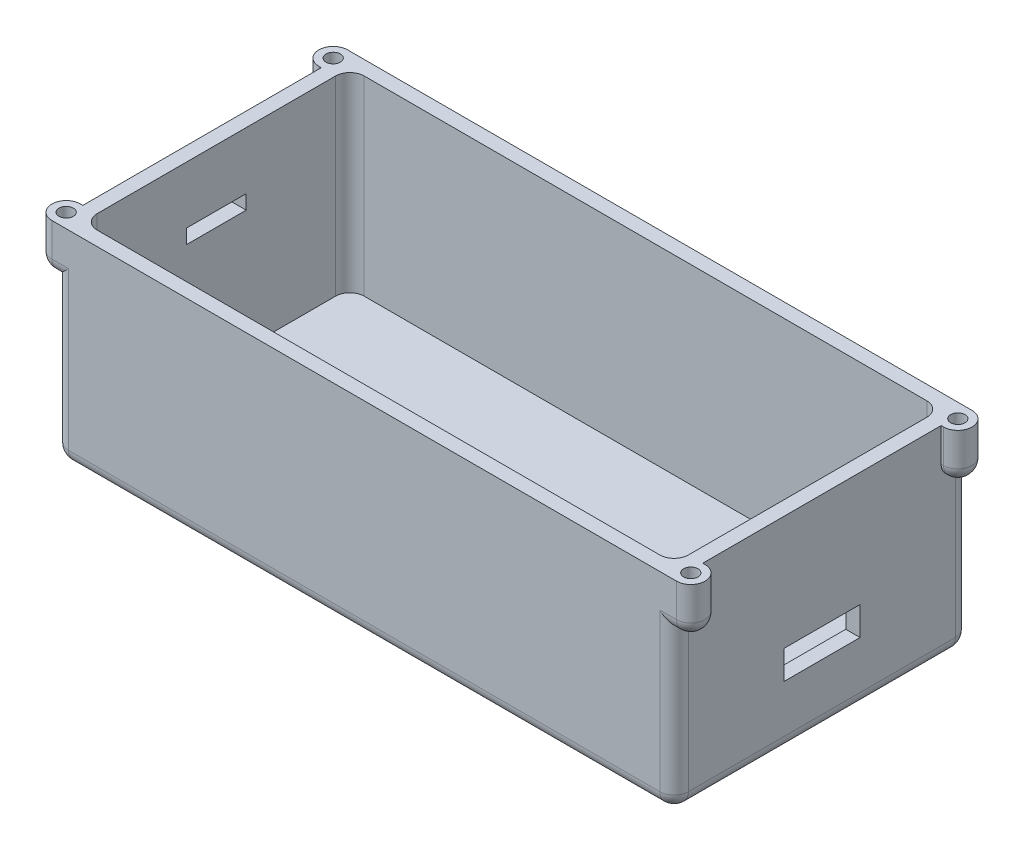
from build123d import *

# Parameters (mm, degrees)
SKETCH1_W           = 130
SKETCH1_H           = 62
BOSS_EXTRUDE1_DEPTH = 3
SKETCH2_W           = 130
SKETCH2_H           = 62
SKETCH2_W_2         = 124
SKETCH2_H_2         = 56
BOSS_EXTRUDE2_DEPTH = 40
CUT_EXTRUDE1_REACH  = 132
SKETCH3_W           = 16
SKETCH3_H           = 6
CUT_EXTRUDE2_REACH  = 132
SKETCH4_W           = 12.5
SKETCH4_H           = 3
BOSS_EXTRUDE3_DEPTH = 10
SKETCH6_R           = 1.5
CUT_EXTRUDE3_DEPTH  = 5
FILLET1_R           = 3
FILLET2_R           = 3
FILLET3_R           = 3


with BuildPart() as part:
    # Sketch1 → Boss-Extrude1 (new body)
    with BuildSketch(Plane(origin=(0, 0, 0), x_dir=(1, 0, 0), z_dir=(0, 1, 0))):
        Rectangle(SKETCH1_W, SKETCH1_H)
    extrude(amount=BOSS_EXTRUDE1_DEPTH)

    # Sketch2 → Boss-Extrude2 (add)
    with BuildSketch(Plane(origin=(0, 3, 0), x_dir=(1, 0, 0), z_dir=(0, 1, 0))):
        Rectangle(SKETCH2_W, SKETCH2_H)
        Rectangle(SKETCH2_W_2, SKETCH2_H_2, mode=Mode.SUBTRACT)
    extrude(amount=BOSS_EXTRUDE2_DEPTH)

    # Sketch3 → Cut-Extrude1 (cut, up to next)
    with BuildSketch(Plane(origin=(65, 0, 0), x_dir=(0, 0, -1), z_dir=(1, 0, 0)), mode=Mode.PRIVATE) as cut_extrude1_sk1:
        with Locations((0, 16)):
            Rectangle(SKETCH3_W, SKETCH3_H)
    cut_extrude1_tool1 = extrude(cut_extrude1_sk1.sketch, amount=-CUT_EXTRUDE1_REACH, mode=Mode.PRIVATE) & part.part
    add(cut_extrude1_tool1.solids().sort_by_distance((65, 16, 0))[0], mode=Mode.SUBTRACT)

    # Sketch4 → Cut-Extrude2 (cut, up to next)
    with BuildSketch(Plane.ZY.offset(65), mode=Mode.PRIVATE) as cut_extrude2_sk1:
        with Locations((0, 29.5)):
            Rectangle(SKETCH4_W, SKETCH4_H)
    cut_extrude2_tool1 = extrude(cut_extrude2_sk1.sketch, amount=-CUT_EXTRUDE2_REACH, mode=Mode.PRIVATE) & part.part
    add(cut_extrude2_tool1.solids().sort_by_distance((-65, 29.5, 0))[0], mode=Mode.SUBTRACT)

    # Sketch5 → Boss-Extrude3 (add)
    with BuildSketch(Plane(origin=(0, 43, 0), x_dir=(1, 0, 0), z_dir=(0, 1, 0))):
        with BuildLine():
            Line((-65, 31), (-65.5, 31))
            ThreePointArc((-65.5, 31), (-68.5, 28), (-65.5, 25))
            Line((-65.5, 25), (-65, 25))
            Line((-65, 25), (-65, 31))
        make_face()
        with BuildLine():
            Line((-65.5, -25), (-65, -25))
            Line((-65, -25), (-65, -31))
            Line((-65, -31), (-65.5, -31))
            ThreePointArc((-65.5, -31), (-68.5, -28), (-65.5, -25))
        make_face()
        with BuildLine():
            Line((65.5, 25), (65, 25))
            Line((65, 25), (65, 31))
            Line((65, 31), (65.5, 31))
            ThreePointArc((65.5, 31), (68.5, 28), (65.5, 25))
        make_face()
        with BuildLine():
            Line((65.5, -25), (65, -25))
            Line((65, -25), (65, -31))
            Line((65, -31), (65.5, -31))
            ThreePointArc((65.5, -31), (68.5, -28), (65.5, -25))
        make_face()
    extrude(amount=-BOSS_EXTRUDE3_DEPTH)

    # Sketch6 → Cut-Extrude3 (cut)
    with BuildSketch(Plane(origin=(0, 43, 0), x_dir=(1, 0, 0), z_dir=(0, 1, 0))):
        with Locations((-65.5, 28)):
            Circle(SKETCH6_R)
        with Locations((-65.5, -28)):
            Circle(SKETCH6_R)
        with Locations((65.5, -28)):
            Circle(SKETCH6_R)
        with Locations((65.5, 28)):
            Circle(SKETCH6_R)
    extrude(amount=-CUT_EXTRUDE3_DEPTH, mode=Mode.SUBTRACT)

    # Fillet1
    fillet1_edges = [part.edges().sort_by_distance(p)[0] for p in [
        (-65, 16.5, 31),
        (65, 16.5, -31),
        (65, 16.5, 31),
        (-62, 23, 28),
        (62, 23, 28),
        (62, 23, -28),
        (-62, 23, -28),
        (-65, 16.5, -31),
    ]]
    fillet(fillet1_edges, radius=FILLET1_R)

    # Fillet2
    fillet2_edges = [part.edges().sort_by_distance(p)[0] for p in [
        (65.25, 33, -25),
        (63.5, 33, -31),
        (63.5, 33, 31),
        (65.25, 33, 25),
        (-63.5, 33, -31),
        (-65.25, 33, -25),
        (-65.25, 33, 25),
        (-63.5, 33, 31),
        (68.5, 33, -28),
        (68.5, 33, 28),
        (-68.5, 33, -28),
        (-68.5, 33, 28),
    ]]
    fillet(fillet2_edges, radius=FILLET2_R)

    # Fillet3
    fillet3_edges = [part.edges().sort_by_distance(p)[0] for p in [
        (0, 0, 31),
        (65, 0, 0),
        (-65, 0, 0),
        (0, 0, -31),
        (-64.121320344, 0, -30.121320344),
        (64.121320344, 0, -30.121320344),
        (64.121320344, 0, 30.121320344),
        (-64.121320344, 0, 30.121320344),
    ]]
    fillet(fillet3_edges, radius=FILLET3_R)


solid = part.part
